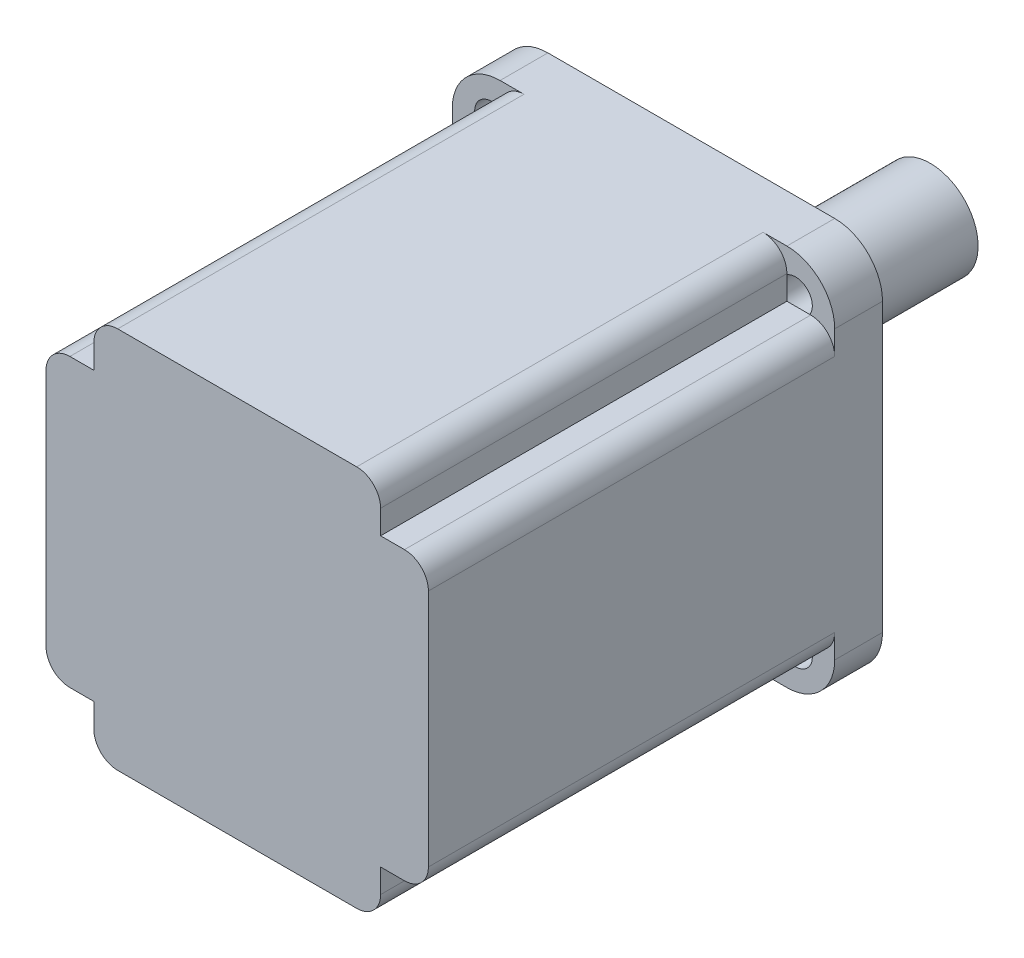
from build123d import *

# Parameters (mm, degrees)
SKETCH_1_W          = 80
SKETCH_1_H          = 80
EXTRUDE_1_DEPTH     = 95
SKETCH_2_R          = 10
EXTRUDE_2_DEPTH     = 50
SKETCH_3_W          = 10
SKETCH_3_H          = 10
CUT_EXTRUDE_1_DEPTH = 85
FILLET_1_R          = 10
FILLET_3_R          = 5
MM_1_AT_2_COUNT     = 2
MM_1_AT_2_PITCH     = 63.639610307
MM_1_AT_3_COUNT     = 2
MM_1_AT_3_PITCH     = 90
MM_1_AT_4_COUNT     = 2
MM_1_AT_4_PITCH     = 63.639610307


with BuildPart() as part:
    # 草图1 → 凸台-拉伸1 (new body)
    with BuildSketch(Plane.XY):
        Rectangle(SKETCH_1_W, SKETCH_1_H)
    extrude(amount=EXTRUDE_1_DEPTH)

    # 草图2 → 凸台-拉伸2 (add)
    with BuildSketch(Plane(origin=(0, 0, 0), x_dir=(-1, 0, 0), z_dir=(0, 0, -1))):
        Circle(SKETCH_2_R)
    extrude(amount=EXTRUDE_2_DEPTH)

    # 草图3 → 切除-拉伸1 (cut)
    with BuildSketch(Plane.XY.offset(95)):
        with Locations((-35, 35)):
            Rectangle(SKETCH_3_W, SKETCH_3_H)
        with Locations((35, 35)):
            Rectangle(SKETCH_3_W, SKETCH_3_H)
        with Locations((35, -35)):
            Rectangle(SKETCH_3_W, SKETCH_3_H)
        with Locations((-35, -35)):
            Rectangle(SKETCH_3_W, SKETCH_3_H)
    extrude(amount=-CUT_EXTRUDE_1_DEPTH, mode=Mode.SUBTRACT)

    # 圆角1
    fillet_1_edges = [part.edges().sort_by_distance(p)[0] for p in [
        (40, 40, 5),
        (40, -40, 5),
        (-40, 40, 5),
        (-40, -40, 5),
    ]]
    fillet(fillet_1_edges, radius=FILLET_1_R)

    # 圆角3
    fillet_3_edges = [part.edges().sort_by_distance(p)[0] for p in [
        (-30, -40, 52.5),
        (-40, -30, 52.5),
        (40, -30, 52.5),
        (30, -40, 52.5),
        (30, 40, 52.5),
        (40, 30, 52.5),
        (-40, 30, 52.5),
        (-30, 40, 52.5),
    ]]
    fillet(fillet_3_edges, radius=FILLET_3_R)

    # 草图5 → 大小mm 暗销槽口1 (revolve, cut)
    with BuildSketch(Plane(origin=(-31.819805153, 31.819805153, 10), x_dir=(0, -1, 0), z_dir=(1, 0, 0))):
        Polygon((0, 0), (0, 62.103012167), (3.5, 60), (3.5, 0), align=None)
    mm_1 = revolve(axis=Axis((-31.819805153, 31.819805153, 16.35), (0, 0, -1)), mode=Mode.SUBTRACT)

    # 大小mm 暗销槽口1 at 2: 大小mm 暗销槽口1 ×2
    with Locations(*[(i * MM_1_AT_2_PITCH, 0, 0) for i in range(1, MM_1_AT_2_COUNT)]):
        add(mm_1, mode=Mode.SUBTRACT)

    # 大小mm 暗销槽口1 at 3: 大小mm 暗销槽口1 ×2
    with Locations(*[Vector(0.707106781, -0.707106781, 0) * (i * MM_1_AT_3_PITCH) for i in range(1, MM_1_AT_3_COUNT)]):
        add(mm_1, mode=Mode.SUBTRACT)

    # 大小mm 暗销槽口1 at 4: 大小mm 暗销槽口1 ×2
    with Locations(*[(0, -i * MM_1_AT_4_PITCH, 0) for i in range(1, MM_1_AT_4_COUNT)]):
        add(mm_1, mode=Mode.SUBTRACT)


solid = part.part
